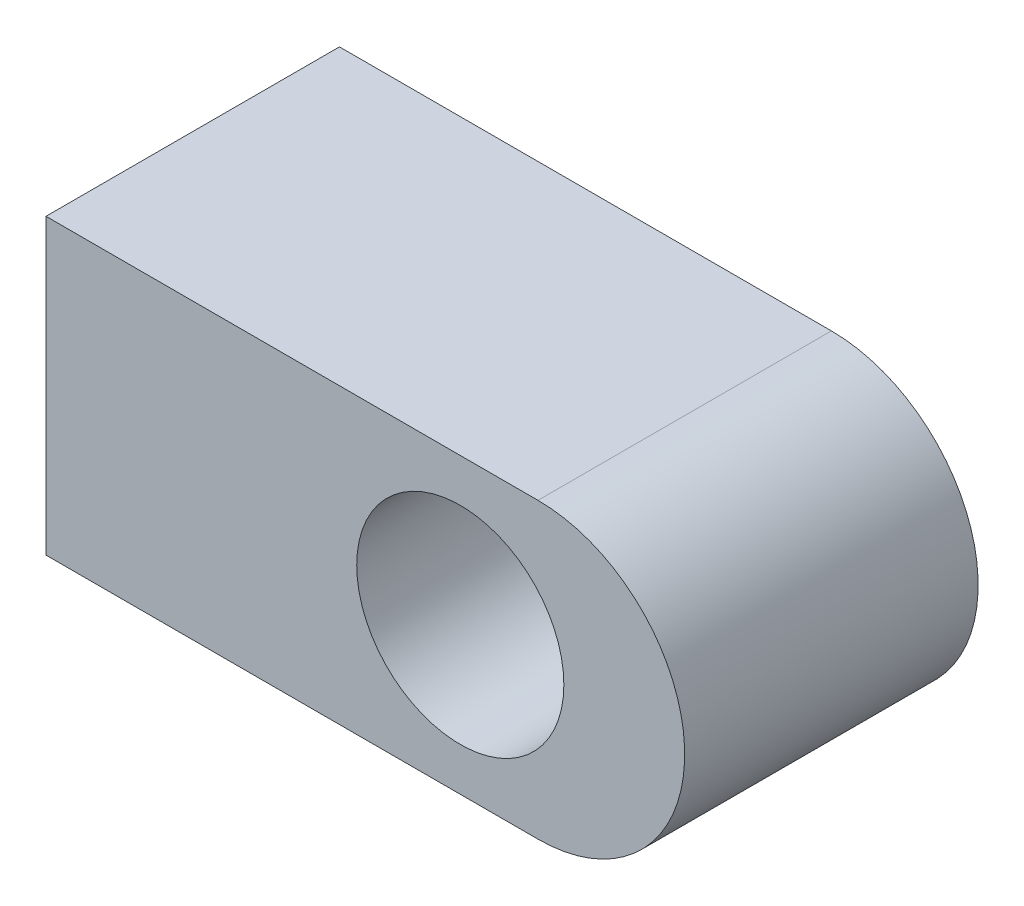
from build123d import *

# Parameters (mm, degrees)
DODANIE_WYCI_GNI_CIE6_DEPTH      = 17
DODANIE_WYCI_GNI_CIE6_DEPTH_BACK = 17
SZKIC1_R                         = 12


with BuildPart() as part:
    # Szkic1 → Dodanie-wyciągnięcie6 (new, two sides: drawn at the far end of the back side and taken through both)
    with BuildSketch(Plane.XY.offset(-DODANIE_WYCI_GNI_CIE6_DEPTH_BACK)):
        with BuildLine():
            Line((4.970807503, 27.515463918), (-43.029192497, 27.515463918))
            Line((-43.029192497, 27.515463918), (-43.029192497, -6.484536082))
            Line((-43.029192497, -6.484536082), (4.970807503, -6.484536082))
            Line((4.970807503, -6.484536082), (13.970807503, -6.484536082))
            ThreePointArc((13.970807503, -6.484536082), (25.991622783, -1.505351363), (30.970807503, 10.515463918))
            ThreePointArc((30.970807503, 10.515463918), (25.991622783, 22.536279198), (13.970807503, 27.515463918))
            Line((13.970807503, 27.515463918), (4.970807503, 27.515463918))
        make_face()
        with Locations((4.970807503, 10.515463918)):
            Circle(SZKIC1_R, mode=Mode.SUBTRACT)
    extrude(amount=DODANIE_WYCI_GNI_CIE6_DEPTH + DODANIE_WYCI_GNI_CIE6_DEPTH_BACK)


solid = part.part
